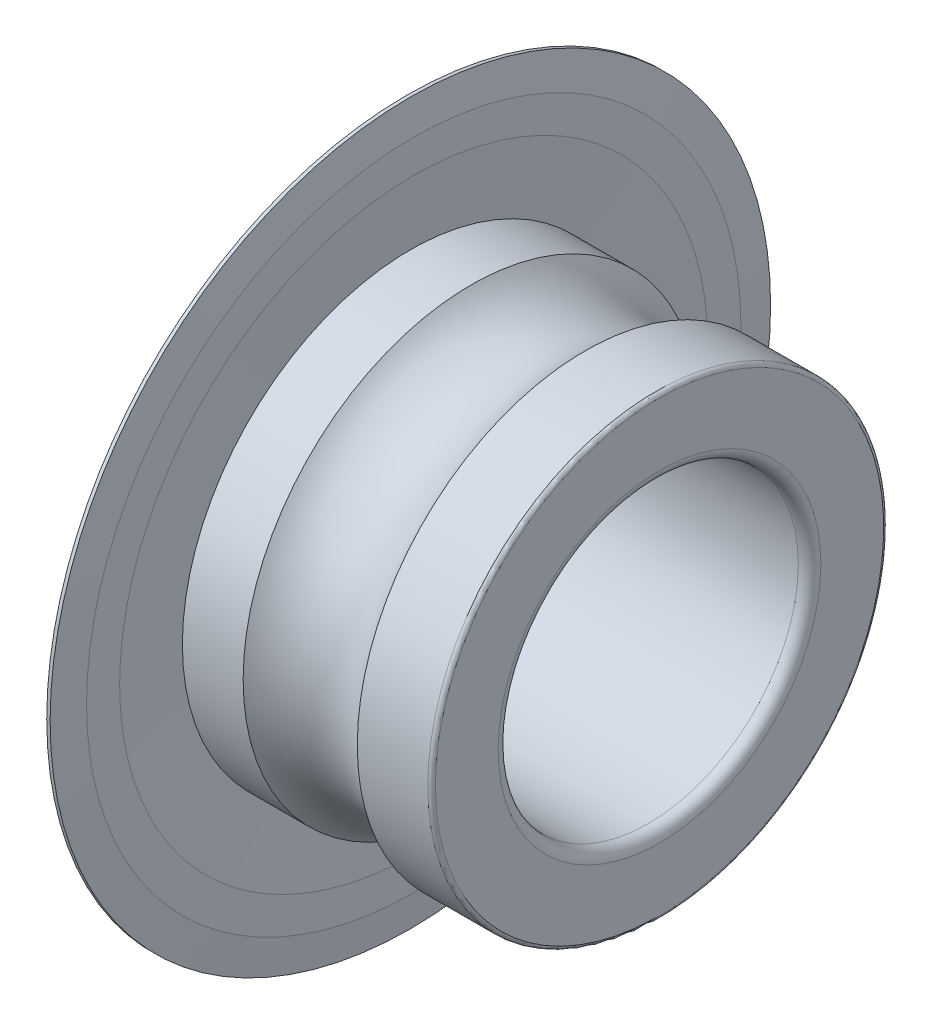
from build123d import *


with BuildPart() as part:
    # Skizze1 → Rotation1 (revolve)
    with BuildSketch(Plane.XY):
        with BuildLine():
            Line((0, 5.975), (0, 4.3))
            ThreePointArc((0, 4.3), (0.087867966, 4.087867966), (0.3, 4))
            Line((0.3, 4), (6.7, 4))
            ThreePointArc((6.7, 4), (6.912132034, 4.087867966), (7, 4.3))
            Line((7, 4.3), (7, 5.975))
            ThreePointArc((7, 5.975), (6.970710678, 6.045710678), (6.9, 6.075))
            Line((6.9, 6.075), (5.020728526, 6.075))
            ThreePointArc((5.020728526, 6.075), (3.5, 5.3655), (1.979271474, 6.075))
            Line((1.979271474, 6.075), (0.1, 6.075))
            ThreePointArc((0.1, 6.075), (0.029289322, 6.045710678), (0, 5.975))
        make_face()
    revolve(axis=Axis((50, 0, 0), (-1, 0, 0)))

    # Skizze2 → Rotation2 (revolve)
    with BuildSketch(Plane.XY):
        Polygon((0.27, 9.6), (0.315, 8.71875), (0.27, 7.8375), (0.27, 6.075), (0.36, 6.075), (0.45, 7.8375), (0.45, 8.71875), (0.36, 9.6), align=None)
    revolve(axis=Axis((50, 0, 0), (-1, 0, 0)))


solid = part.part
